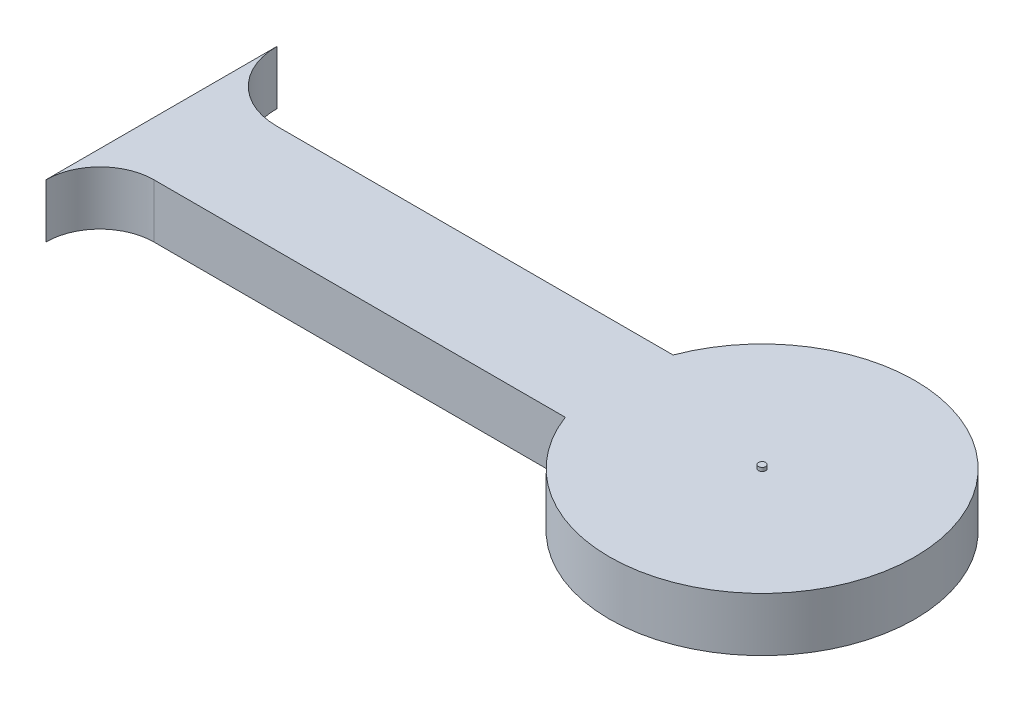
from build123d import *

# Parameters (mm, degrees)
RESSALTO_EXTRUS_O1_DEPTH = 1.5
ESBO_O2_R                = 0.1
RESSALTO_EXTRUS_O2_DEPTH = 0.1


with BuildPart() as part:
    # Esboço1 → Ressalto-extrusão1 (new body)
    with BuildSketch(Plane(origin=(0, 0, 0), x_dir=(1, 0, 0), z_dir=(0, 1, 0))):
        with BuildLine():
            Line((-3.97649343, 1.5), (-15, 1.5))
            ThreePointArc((-15, 1.5), (-16.358835062, 2.062847912), (-16.921682974, 3.421682974))
            Line((-16.921682974, 3.421682974), (-16.921682974, -3))
            ThreePointArc((-16.921682974, -3), (-16.482343146, -1.939339828), (-15.421682974, -1.5))
            Line((-15.421682974, -1.5), (-3.97649343, -1.5))
            ThreePointArc((-3.97649343, -1.5), (4.25, 0), (-3.97649343, 1.5))
        make_face()
    extrude(amount=RESSALTO_EXTRUS_O1_DEPTH)

    # Esboço2 → Ressalto-extrusão2 (add)
    with BuildSketch(Plane(origin=(0, 1.5, 0), x_dir=(1, 0, 0), z_dir=(0, 1, 0))):
        Circle(ESBO_O2_R)
    extrude(amount=RESSALTO_EXTRUS_O2_DEPTH)


solid = part.part
